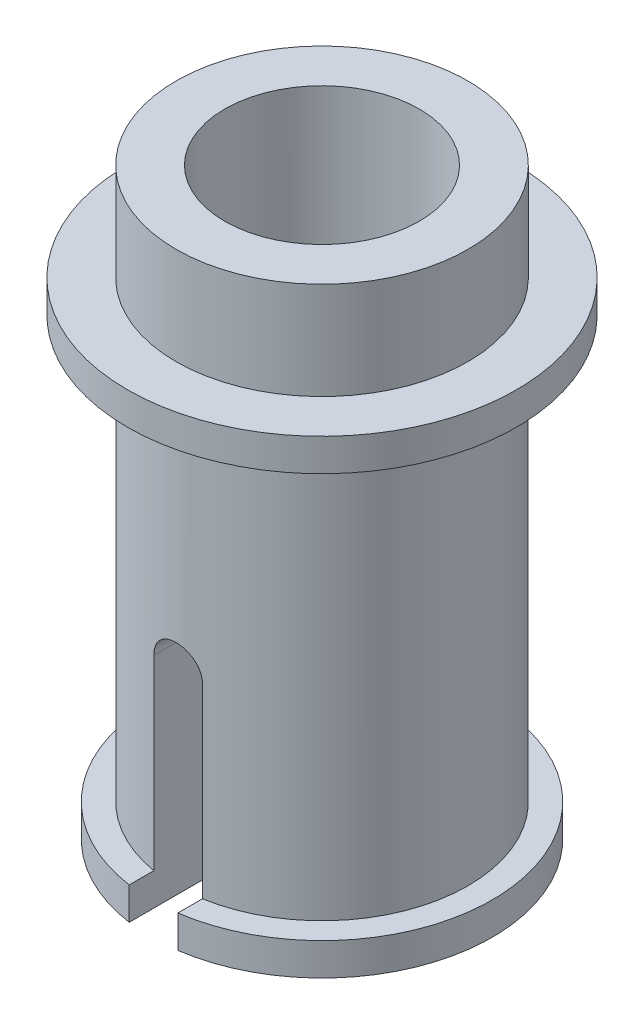
from build123d import *

# Parameters (mm, degrees)
SKETCH2_R               = 1.5
SKETCH2_R_2             = 1
BOSS_EXTRUDE2_DEPTH     = 5
SKETCH2_3_R             = 1.75
SKETCH2_3_R_2           = 1.5
BOSS_EXTRUDE3_DEPTH     = 0.333333333
SKETCH3_R               = 2
SKETCH3_R_2             = 1.5
BOSS_EXTRUDE4_DEPTH     = 0.333333333
SKETCH3_3_R             = 1.5
SKETCH3_3_R_2           = 1
BOSS_EXTRUDE5_DEPTH     = 1
SKETCH5_R               = 0.25
SKETCH5_W               = 0.5
SKETCH5_H               = 2.25
CUT_EXTRUDE1_DEPTH      = 2
CUT_EXTRUDE1_DEPTH_BACK = 2


with BuildPart() as part:
    # Sketch2 → Boss-Extrude2 (new body)
    with BuildSketch(Plane(origin=(0, 0, 0), x_dir=(1, 0, 0), z_dir=(0, 1, 0))):
        Circle(SKETCH2_R)
        Circle(SKETCH2_R_2, mode=Mode.SUBTRACT)
    extrude(amount=BOSS_EXTRUDE2_DEPTH)

    # Sketch2_3 → Boss-Extrude3 (add)
    with BuildSketch(Plane(origin=(0, 0, 0), x_dir=(1, 0, 0), z_dir=(0, 1, 0))):
        Circle(SKETCH2_3_R)
        Circle(SKETCH2_3_R_2, mode=Mode.SUBTRACT)
    extrude(amount=BOSS_EXTRUDE3_DEPTH)

    # Sketch3 → Boss-Extrude4 (add)
    with BuildSketch(Plane(origin=(0, 5, 0), x_dir=(-1, 0, 0), z_dir=(0, 1, 0))):
        Circle(SKETCH3_R)
        Circle(SKETCH3_R_2, mode=Mode.SUBTRACT)
    extrude(amount=-BOSS_EXTRUDE4_DEPTH)

    # Sketch3_3 → Boss-Extrude5 (add)
    with BuildSketch(Plane(origin=(0, 5, 0), x_dir=(-1, 0, 0), z_dir=(0, 1, 0))):
        Circle(SKETCH3_3_R)
        Circle(SKETCH3_3_R_2, mode=Mode.SUBTRACT)
    extrude(amount=BOSS_EXTRUDE5_DEPTH)

    # Sketch5 → Cut-Extrude1 (cut, two sides)
    with BuildSketch(Plane.XY) as cut_extrude1_sk:
        with Locations((0, 2.25)):
            Circle(SKETCH5_R)
        with Locations((0, 1.125)):
            Rectangle(SKETCH5_W, SKETCH5_H)
    extrude(amount=CUT_EXTRUDE1_DEPTH, mode=Mode.SUBTRACT)
    extrude(cut_extrude1_sk.sketch, amount=-CUT_EXTRUDE1_DEPTH_BACK, mode=Mode.SUBTRACT)


solid = part.part
